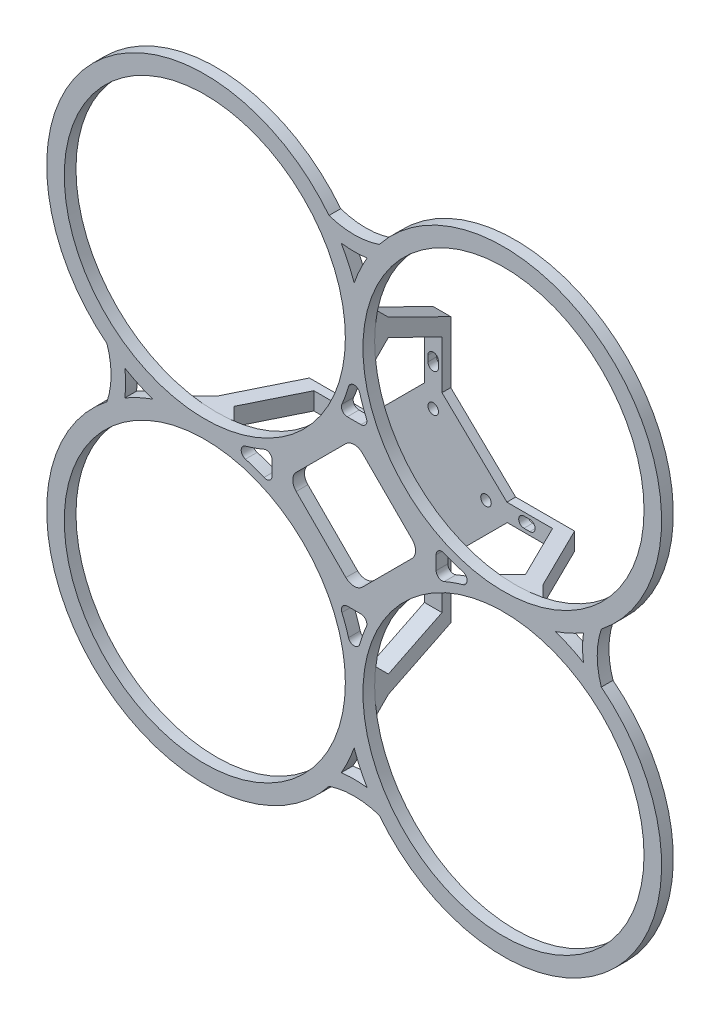
from build123d import *

# Parameters (mm, degrees)
SKETCH_1_R               = 46
SKETCH_1_R_2             = 1.8
EXTRUDE_1_DEPTH          = 4
SKETCH_4_R               = 1.8
EXTRUDE_2_DEPTH          = 3
EXTRUDE_3_DEPTH          = 3
PATTERN_CIRCULAR_1_COUNT = 4
CUT_EXTRUDE_3_DEPTH      = 30
CUT_EXTRUDE_4_DEPTH      = 3
PATTERN_CIRCULAR_2_COUNT = 4
SKETCH_22_W              = 3
SKETCH_22_H              = 3
EXTRUDE_6_DEPTH          = 1
PATTERN_CIRCULAR_8_COUNT = 4
EXTRUDE_7_DEPTH          = 4
SKETCH_25_R              = 48
CUT_EXTRUDE_5_DEPTH      = 4


with BuildPart() as part:
    # 草图1 → 凸台-拉伸1 (new body)
    with BuildSketch(Plane.XY):
        with BuildLine():
            ThreePointArc((-17.648363843, -89.583265358), (0, -83.012821567), (17.648363843, -89.583265358))
            ThreePointArc((17.648363843, -89.583265358), (87.062445841, -87.062445841), (89.583265358, -17.648363843))
            ThreePointArc((89.583265358, -17.648363843), (83.012821567, 0), (89.583265358, 17.648363843))
            ThreePointArc((89.583265358, 17.648363843), (87.062445841, 87.062445841), (17.648363843, 89.583265358))
            ThreePointArc((17.648363843, 89.583265358), (0, 83.012821567), (-17.648363843, 89.583265358))
            ThreePointArc((-17.648363843, 89.583265358), (-87.062445841, 87.062445841), (-89.583265358, 17.648363843))
            ThreePointArc((-89.583265358, 17.648363843), (-83.012821567, 0), (-89.583265358, -17.648363843))
            ThreePointArc((-89.583265358, -17.648363843), (-87.062445841, -87.062445841), (-17.648363843, -89.583265358))
        make_face()
        with Locations((51, -51)):
            Circle(SKETCH_1_R, mode=Mode.SUBTRACT)
        with Locations((-51, -51)):
            Circle(SKETCH_1_R, mode=Mode.SUBTRACT)
        with BuildLine():
            ThreePointArc((-51, 0), (-65.702441614, -2.165194681), (-79.15650486, -8.476932918))
            ThreePointArc((-79.15650486, -8.476932918), (-78.012821567, 0), (-79.15650486, 8.476932918))
            ThreePointArc((-79.15650486, 8.476932918), (-65.702441614, 2.165194681), (-51, 0))
        make_face(mode=Mode.SUBTRACT)
        with Locations((-18.03122292, 0)):
            Circle(SKETCH_1_R_2, mode=Mode.SUBTRACT)
        with BuildLine():
            ThreePointArc((0, -51), (2.165194681, -65.702441614), (8.476932918, -79.15650486))
            ThreePointArc((8.476932918, -79.15650486), (0, -78.012821567), (-8.476932918, -79.15650486))
            ThreePointArc((-8.476932918, -79.15650486), (-2.165194681, -65.702441614), (0, -51))
        make_face(mode=Mode.SUBTRACT)
        with BuildLine():
            Line((-2.337899758, -28), (2.337899758, -28))
            ThreePointArc((2.337899758, -28), (4.008963141, -28.901115488), (4.174205427, -30.79245283))
            ThreePointArc((4.174205427, -30.79245283), (2.945040819, -33.920161063), (1.924528302, -37.122029053))
            ThreePointArc((1.924528302, -37.122029053), (0, -38.577794898), (-1.924528302, -37.122029053))
            ThreePointArc((-1.924528302, -37.122029053), (-2.945040819, -33.920161063), (-4.174205427, -30.79245283))
            ThreePointArc((-4.174205427, -30.79245283), (-4.008963141, -28.901115488), (-2.337899758, -28))
        make_face(mode=Mode.SUBTRACT)
        with Locations((0, -18.03122292)):
            Circle(SKETCH_1_R_2, mode=Mode.SUBTRACT)
        Polygon((9.899494937, 0), (0, -9.899494937), (-9.899494937, 0), (0, 9.899494937), align=None, mode=Mode.SUBTRACT)
        with Locations((18.03122292, 0)):
            Circle(SKETCH_1_R_2, mode=Mode.SUBTRACT)
        with BuildLine():
            Line((28, -2.337899758), (28, 2.337899758))
            ThreePointArc((28, 2.337899758), (28.901115488, 4.008963141), (30.79245283, 4.174205427))
            ThreePointArc((30.79245283, 4.174205427), (33.920161063, 2.945040819), (37.122029053, 1.924528302))
            ThreePointArc((37.122029053, 1.924528302), (38.577794898, 0), (37.122029053, -1.924528302))
            ThreePointArc((37.122029053, -1.924528302), (33.920161063, -2.945040819), (30.79245283, -4.174205427))
            ThreePointArc((30.79245283, -4.174205427), (28.901115488, -4.008963141), (28, -2.337899758))
        make_face(mode=Mode.SUBTRACT)
        with BuildLine():
            Line((-28, 2.337899758), (-28, -2.337899758))
            ThreePointArc((-28, -2.337899758), (-28.901115488, -4.008963141), (-30.79245283, -4.174205427))
            ThreePointArc((-30.79245283, -4.174205427), (-33.920161063, -2.945040819), (-37.122029053, -1.924528302))
            ThreePointArc((-37.122029053, -1.924528302), (-38.577794898, 0), (-37.122029053, 1.924528302))
            ThreePointArc((-37.122029053, 1.924528302), (-33.920161063, 2.945040819), (-30.79245283, 4.174205427))
            ThreePointArc((-30.79245283, 4.174205427), (-28.901115488, 4.008963141), (-28, 2.337899758))
        make_face(mode=Mode.SUBTRACT)
        with Locations((-51, 51)):
            Circle(SKETCH_1_R, mode=Mode.SUBTRACT)
        with Locations((0, 18.03122292)):
            Circle(SKETCH_1_R_2, mode=Mode.SUBTRACT)
        with BuildLine():
            ThreePointArc((1.924528302, 37.122029053), (2.945040819, 33.920161063), (4.174205427, 30.79245283))
            ThreePointArc((4.174205427, 30.79245283), (4.008963141, 28.901115488), (2.337899758, 28))
            Line((2.337899758, 28), (-2.337899758, 28))
            ThreePointArc((-2.337899758, 28), (-4.008963141, 28.901115488), (-4.174205427, 30.79245283))
            ThreePointArc((-4.174205427, 30.79245283), (-2.945040819, 33.920161063), (-1.924528302, 37.122029053))
            ThreePointArc((-1.924528302, 37.122029053), (0, 38.577794898), (1.924528302, 37.122029053))
        make_face(mode=Mode.SUBTRACT)
        with BuildLine():
            ThreePointArc((79.15650486, 8.476932918), (78.012821567, 0), (79.15650486, -8.476932918))
            ThreePointArc((79.15650486, -8.476932918), (65.702441614, -2.165194681), (51, 0))
            ThreePointArc((51, 0), (65.702441614, 2.165194681), (79.15650486, 8.476932918))
        make_face(mode=Mode.SUBTRACT)
        with BuildLine():
            ThreePointArc((-8.476932918, 79.15650486), (0, 78.012821567), (8.476932918, 79.15650486))
            ThreePointArc((8.476932918, 79.15650486), (2.165194681, 65.702441614), (0, 51))
            ThreePointArc((0, 51), (-2.165194681, 65.702441614), (-8.476932918, 79.15650486))
        make_face(mode=Mode.SUBTRACT)
        with Locations((51, 51)):
            Circle(SKETCH_1_R, mode=Mode.SUBTRACT)
    extrude(amount=EXTRUDE_1_DEPTH)

    # 草图8 → 凸台-拉伸3 (add, symmetric)
    with BuildSketch(Plane(origin=(0, 0, 0), x_dir=(0, 0, -1), z_dir=(1, 0, 0))):
        Polygon((23, 20.450291093), (23, 40.757425202), (4.692917013, 49.776091208), (0, 45.083174196), (0, 60.469008221), (4.692917013, 55.776091208), (26, 45.279527383), (26, 43.279527383), (26, 20.450291093), align=None)
    extrude_3 = extrude(amount=EXTRUDE_3_DEPTH, both=True)

    # 阵列(圆周)1: 凸台-拉伸3 ×4 about axis
    pattern_circular_1_axis = Axis((0, 0, 0), (0, 0, 1))
    for i in range(1, PATTERN_CIRCULAR_1_COUNT):
        add(extrude_3.rotate(pattern_circular_1_axis, i * 360 / PATTERN_CIRCULAR_1_COUNT))

    # 草图12 → 切除-拉伸3 (cut, symmetric)
    with BuildSketch(Plane.XY.offset(-23)):
        with BuildLine():
            Line((-19.798989873, -2.828427125), (-2.828427125, -19.798989873))
            ThreePointArc((-2.828427125, -19.798989873), (0, -20.970562748), (2.828427125, -19.798989873))
            Line((2.828427125, -19.798989873), (19.798989873, -2.828427125))
            ThreePointArc((19.798989873, -2.828427125), (20.970562748, 0), (19.798989873, 2.828427125))
            Line((19.798989873, 2.828427125), (2.828427125, 19.798989873))
            ThreePointArc((2.828427125, 19.798989873), (0, 20.970562748), (-2.828427125, 19.798989873))
            Line((-2.828427125, 19.798989873), (-19.798989873, 2.828427125))
            ThreePointArc((-19.798989873, 2.828427125), (-20.970562748, 0), (-19.798989873, -2.828427125))
        make_face()
    extrude(amount=CUT_EXTRUDE_3_DEPTH, both=True, mode=Mode.SUBTRACT)

    # 草图13 → 切除-拉伸4 (cut)
    with BuildSketch(Plane(origin=(0, 0, -26), x_dir=(-1, 0, 0), z_dir=(0, 0, -1))):
        with BuildLine():
            Line((1.8, 33), (1.8, 31))
            ThreePointArc((1.8, 31), (0, 29.2), (-1.8, 31))
            Line((-1.8, 31), (-1.8, 33))
            ThreePointArc((-1.8, 33), (0, 34.8), (1.8, 33))
        make_face()
    cut_extrude_4 = extrude(amount=-CUT_EXTRUDE_4_DEPTH, mode=Mode.SUBTRACT)

    # 阵列(圆周)2: 切除-拉伸4 ×4 about axis
    pattern_circular_2_axis = Axis((0, 0, 0), (0, 0, 1))
    for i in range(1, PATTERN_CIRCULAR_2_COUNT):
        add(cut_extrude_4.rotate(pattern_circular_2_axis, i * 360 / PATTERN_CIRCULAR_2_COUNT), mode=Mode.SUBTRACT)



with BuildPart() as body_2:
    # 草图4 → 凸台-拉伸2 (new body)
    with BuildSketch(Plane.XY.offset(-26)):
        Polygon((-27.179581891, 0), (0, 27.179581891), (28.284271247, 0), (0, -28.284271247), align=None)
        with Locations((0, 18.03122292)):
            Circle(SKETCH_4_R, mode=Mode.SUBTRACT)
        with Locations((18.03122292, 0)):
            Circle(SKETCH_4_R, mode=Mode.SUBTRACT)
        with Locations((0, -18.03122292)):
            Circle(SKETCH_4_R, mode=Mode.SUBTRACT)
        with Locations((-18.03122292, 0)):
            Circle(SKETCH_4_R, mode=Mode.SUBTRACT)
    extrude(amount=EXTRUDE_2_DEPTH)


with BuildPart() as part_1:
    add(part.part)

    add(body_2.part)  # 凸台-拉伸6 merges body 2
    # 草图22 → 凸台-拉伸6 (add)
    with BuildSketch(Plane.ZY.offset(3)):
        with Locations((-24.5, 25.679581891)):
            Rectangle(SKETCH_22_W, SKETCH_22_H)
    extrude_6 = extrude(amount=-EXTRUDE_6_DEPTH)

    # 阵列(圆周)8: 凸台-拉伸6 ×4 about axis
    pattern_circular_8_axis = Axis((0, 0, 0), (0, 0, -1))
    for i in range(1, PATTERN_CIRCULAR_8_COUNT):
        add(extrude_6.rotate(pattern_circular_8_axis, i * 360 / PATTERN_CIRCULAR_8_COUNT))

    # 草图24 → 凸台-拉伸7 (add)
    with BuildSketch(Plane.XY.offset(4)):
        with BuildLine():
            ThreePointArc((-68.748239349, 0), (-89.183766184, -89.183766184), (0, -68.748239349))
            ThreePointArc((0, -68.748239349), (89.183766184, -89.183766184), (68.748239349, 0))
            ThreePointArc((68.748239349, 0), (89.183766184, 89.183766184), (0, 68.748239349))
            ThreePointArc((0, 68.748239349), (-89.183766184, 89.183766184), (-68.748239349, 0))
        make_face()
        with BuildLine():
            Line((-5, 51), (5, 51))
            ThreePointArc((5, 51), (83.526911935, 83.526911935), (51, 5))
            Line((51, 5), (51, -5))
            ThreePointArc((51, -5), (83.526911935, -83.526911935), (5, -51))
            Line((5, -51), (-5, -51))
            ThreePointArc((-5, -51), (-83.526911935, -83.526911935), (-51, -5))
            Line((-51, -5), (-51, 5))
            ThreePointArc((-51, 5), (-83.526911935, 83.526911935), (-5, 51))
        make_face(mode=Mode.SUBTRACT)
    extrude(amount=-EXTRUDE_7_DEPTH)

    # 草图25 → 切除-拉伸5 (cut)
    with BuildSketch(Plane.XY.offset(4)):
        with Locations((51, 51)):
            Circle(SKETCH_25_R)
        with Locations((51, -51)):
            Circle(SKETCH_25_R)
        with Locations((-51, -51)):
            Circle(SKETCH_25_R)
        with Locations((-51, 51)):
            Circle(SKETCH_25_R)
    extrude(amount=-CUT_EXTRUDE_5_DEPTH, mode=Mode.SUBTRACT)


solid = part_1.part
